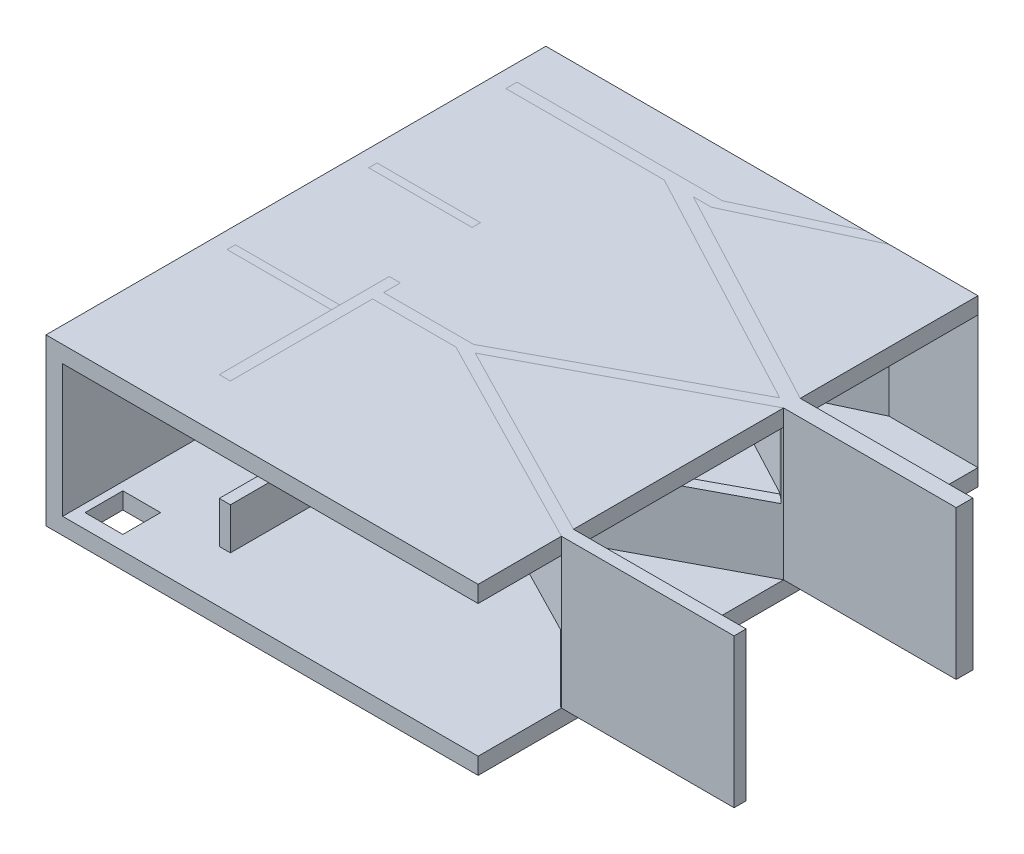
from build123d import *

# Parameters (mm, degrees)
BOSS_EXTRUDE1_DEPTH   = 9000
SKETCH2_W             = 7780
SKETCH2_H             = 2978.231465283
BOSS_EXTRUDE2_DEPTH   = 0.1
SKETCH4_W             = 680.442603136
SKETCH4_H             = 680.442603136
CUT_EXTRUDE1_DEPTH    = 301
BOSS_EXTRUDE3_DEPTH   = 2680
SKETCH11_W            = 3750
SKETCH11_H            = 1150
CUT_EXTRUDE10_DEPTH   = 1199
CUT_EXTRUDE16_DEPTH   = 1199
CUT_EXTRUDE19_DEPTH   = 1199
SKETCH15_W            = 1880
SKETCH15_H            = 150
BOSS_EXTRUDE4_DEPTH   = 1140
BOSS_EXTRUDE5_REACH   = 2682
SKETCH15_2_W          = 1880
SKETCH15_2_H          = 150
BOSS_EXTRUDE6_REACH   = 1542
SKETCH16_W            = 1862
SKETCH16_H            = 150
SKETCH17_W            = 796.936278508
SKETCH17_H            = 50
BOSS_EXTRUDE7_DEPTH   = 2470
SKETCH18_W            = 639.595844291
SKETCH18_H            = 225.322127185
SKETCH18_H_2          = 203.248531495
CUT_EXTRUDE21_DEPTH   = 100
SKETCH19_W            = 74.48
SKETCH19_H            = 74.48
BOSS_EXTRUDE8_DEPTH   = 1510
BOSS_EXTRUDE8_2_DEPTH = 1510
BOSS_EXTRUDE9_DEPTH   = 74.48
SKETCH22_W            = 2020
SKETCH22_H            = 1000
CUT_EXTRUDE22_DEPTH   = 597


with BuildPart() as part:
    # Sketch1 → Boss-Extrude1 (new body)
    with BuildSketch(Plane.XY):
        Polygon((5620, 1.768534717), (5620, 301.768534717), (-2160, 301.768534717), (-2160, -2678.231465283), (5620, -2678.231465283), (5620, -2378.231465283), (50, -2378.231465283), (-1860, -2378.231465283), (-1860, 1.768534717), (-250, 1.768534717), align=None)
    extrude(amount=BOSS_EXTRUDE1_DEPTH)

    # Sketch2 → Boss-Extrude2 (add)
    with BuildSketch(Plane(origin=(0, 0, 0), x_dir=(-1, 0, 0), z_dir=(0, 0, -1))):
        with Locations((-1730, -1189.115732642)):
            Rectangle(SKETCH2_W, SKETCH2_H)
    extrude(amount=BOSS_EXTRUDE2_DEPTH)

    # Sketch4 → Cut-Extrude1 (cut, through all)
    with BuildSketch(Plane(origin=(0, -2378.231465283, 0), x_dir=(1, 0, 0), z_dir=(0, 1, 0))):
        with Locations((-1376.234625342, -8400.221301568)):
            Rectangle(SKETCH4_W, SKETCH4_H)
    extrude(amount=-CUT_EXTRUDE1_DEPTH, mode=Mode.SUBTRACT)

    # Sketch4_9 → Boss-Extrude3 (add, through all)
    with BuildSketch(Plane(origin=(0, -2378.231465283, 0), x_dir=(1, 0, 0), z_dir=(0, 1, 0))):
        Polygon((-1860, -820), (-1860, -1020), (990, -1020), (5428.28891254, -3376.656663831), (1837.547859336, -5300), (220, -5300), (220, -5000), (20, -5000), (20, -8060), (220, -8060), (220, -5500), (1720, -5500), (5620, -7500), (8728.239316984, -7500), (8728.239316984, -7282.729144798), (5620, -7282.729144798), (1988.270990282, -5420.304011609), (5620, -3500), (8728.239316984, -3500), (8728.239316984, -3200), (5620, -3200), (1514.40838887, -1020), (1840, -1020), (4016.829268293, 0), (3590, 0), (1840, -820), align=None)
    extrude(amount=BOSS_EXTRUDE3_DEPTH)

    # Sketch11 → Cut-Extrude10 (cut)
    with BuildSketch(Plane.XZ.offset(-1.768534717)):
        with Locations((3715, 575)):
            Rectangle(SKETCH11_W, SKETCH11_H)
        Polygon((1837.547859336, 5300), (1837.547859336, 3630), (4743.976621723, 3630), (5428.28891254, 3376.656663831), (5590.960805155, 3503.591784624), (5590.960805155, 5232.391121441), (3118.319216172, 5232.391121441), (3118.319216172, 5420.304011609), (1988.270990282, 5420.304011609), (1837.547859336, 5384.175694281), align=None)
    extrude(amount=CUT_EXTRUDE10_DEPTH, mode=Mode.SUBTRACT)

    # Sketch13 → Cut-Extrude16 (cut)
    with BuildSketch(Plane(origin=(0, -2378.231465283, 0), x_dir=(1, 0, 0), z_dir=(0, 1, 0))):
        Polygon((357.775791901, -1020), (5620, -1020), (5620, -3191.666212547), (5403.889674001, -3389.725863798), (357.775791901, -3389.725863798), align=None)
    extrude(amount=CUT_EXTRUDE16_DEPTH, mode=Mode.SUBTRACT)

    # Sketch14 → Cut-Extrude19 (cut)
    with BuildSketch(Plane(origin=(0, -2378.231465283, 0), x_dir=(1, 0, 0), z_dir=(0, 1, 0))):
        Polygon((1347.188843085, -5500), (1837.547859336, -5500), (1988.270990282, -5420.304011609), (2143.678167645, -5500), (5592.480550887, -5500), (5592.480550887, -7500), (1347.188843085, -7500), align=None)
    extrude(amount=CUT_EXTRUDE19_DEPTH, mode=Mode.SUBTRACT)

    # Sketch15 → Boss-Extrude4 (add)
    with BuildSketch(Plane(origin=(0, -2378.231465283, 0), x_dir=(1, 0, 0), z_dir=(0, 1, 0))):
        Polygon((2240, -5084.430670047), (2240, -3490), (-1860, -3490), (-1860, -3340), (2340, -3340), (2340, -5030.86670351), align=None)
        with Locations((-920, -5965)):
            Rectangle(SKETCH15_W, SKETCH15_H)
    extrude(amount=BOSS_EXTRUDE4_DEPTH)

    # Sketch15_2 → Boss-Extrude5 (add, up to next)
    with BuildSketch(Plane(origin=(0, -2378.231465283, 0), x_dir=(1, 0, 0), z_dir=(0, 1, 0)), mode=Mode.PRIVATE) as boss_extrude5_sk1:
        with Locations((-920, -5965)):
            Rectangle(SKETCH15_2_W, SKETCH15_2_H)
    boss_extrude5_tool1 = extrude(boss_extrude5_sk1.sketch, amount=BOSS_EXTRUDE5_REACH, mode=Mode.PRIVATE) - part.part
    add(boss_extrude5_tool1.solids().sort_by_distance((-920, -2378.231465, 5965))[0])

    # Sketch16 → Boss-Extrude6 (add, up to next)
    with BuildSketch(Plane(origin=(0, -1238.231465283, 0), x_dir=(1, 0, 0), z_dir=(0, 1, 0)), mode=Mode.PRIVATE) as boss_extrude6_sk1:
        with Locations((-929, -3415)):
            Rectangle(SKETCH16_W, SKETCH16_H)
    boss_extrude6_tool1 = extrude(boss_extrude6_sk1.sketch, amount=BOSS_EXTRUDE6_REACH, mode=Mode.PRIVATE) - part.part
    add(boss_extrude6_tool1.solids().sort_by_distance((-929, -1238.231465, 3415))[0])

    # Sketch17 → Boss-Extrude7 (add)
    with BuildSketch(Plane.XY.offset(3490)):
        with Locations((400.468139254, -1213.231465283)):
            Rectangle(SKETCH17_W, SKETCH17_H)
    extrude(amount=-BOSS_EXTRUDE7_DEPTH)

    # Sketch18 → Cut-Extrude21 (cut)
    with BuildSketch(Plane(origin=(0, -1188.231465283, 0), x_dir=(1, 0, 0), z_dir=(0, 1, 0))):
        with Locations((403.928784528, -3288.880572499)):
            Rectangle(SKETCH18_W, SKETCH18_H)
        with Locations((403.928784528, -1827.843774654)):
            Rectangle(SKETCH18_W, SKETCH18_H_2)
        with Locations((403.928784528, -2117.843774654)):
            Rectangle(SKETCH18_W, SKETCH18_H_2)
        with Locations((403.928784528, -2407.843774654)):
            Rectangle(SKETCH18_W, SKETCH18_H_2)
        with Locations((403.928784528, -2697.843774654)):
            Rectangle(SKETCH18_W, SKETCH18_H_2)
        with Locations((403.928784528, -2987.843774654)):
            Rectangle(SKETCH18_W, SKETCH18_H_2)
        with Locations((403.928784528, -1537.843774654)):
            Rectangle(SKETCH18_W, SKETCH18_H_2)
        with Locations((403.928784528, -1247.843774654)):
            Rectangle(SKETCH18_W, SKETCH18_H_2)
    extrude(amount=-CUT_EXTRUDE21_DEPTH, mode=Mode.SUBTRACT)

    # Sketch22 → Cut-Extrude22 (cut)
    with BuildSketch(Plane(origin=(220, 0, 0), x_dir=(0, 0, -1), z_dir=(1, 0, 0))):
        with Locations((-7050, -1128.231465283)):
            Rectangle(SKETCH22_W, SKETCH22_H)
    extrude(amount=-CUT_EXTRUDE22_DEPTH, mode=Mode.SUBTRACT)


with BuildPart() as body_2:
    # Sketch19 → Boss-Extrude8 (new body)
    with BuildSketch(Plane.XY.offset(3490)):
        with Locations((-172.76, -15.471465283)):
            Rectangle(SKETCH19_W, SKETCH19_H)
    extrude(amount=BOSS_EXTRUDE8_DEPTH)


with BuildPart() as body_3:
    # Sketch19 → Boss-Extrude8 2 (new body)
    with BuildSketch(Plane.XY.offset(3490)):
        Polygon((-135.52, -1123.731465283), (2.8, -1123.731465283), (2.8, -1228.231465283), (-210, -1228.231465283), (-210, -1100.551465283), (-135.52, -1100.551465283), align=None)
    extrude(amount=BOSS_EXTRUDE8_2_DEPTH)


with BuildPart() as body_4:
    # Sketch21 → Boss-Extrude9 (new body)
    with BuildSketch(Plane(origin=(0, -1238.231465283, 0), x_dir=(1, 0, 0), z_dir=(0, 1, 0))):
        Polygon((810, -3490), (2240, -3490), (2240, -5084.430670047), (1837.547859336, -5300), (810, -5300), align=None)
    extrude(amount=BOSS_EXTRUDE9_DEPTH)


solid = Compound([part.part, body_2.part, body_3.part, body_4.part])
